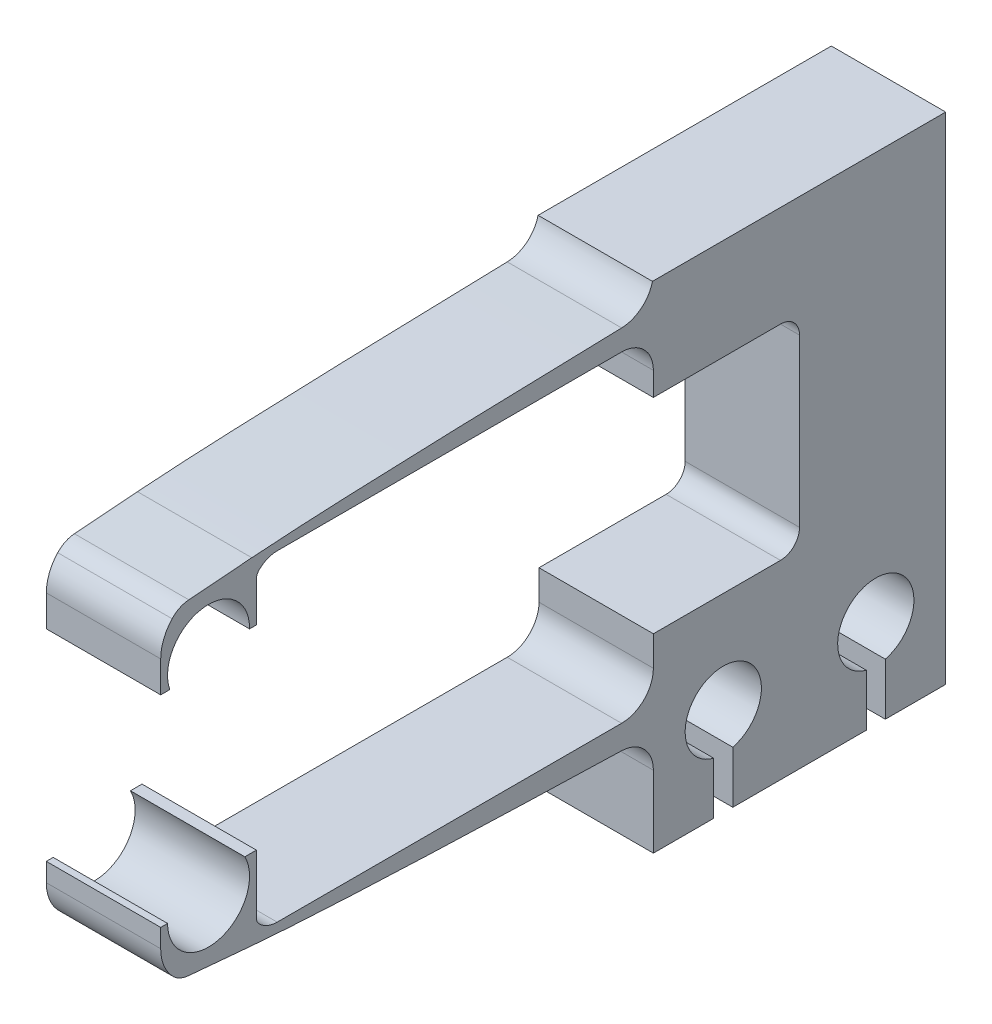
from build123d import *

# Parameters (mm, degrees)
BOSS_EXTRUDE1_DEPTH = 2.25
CUT_EXTRUDE1_DEPTH  = 32.519835025
FILLET1_R           = 0.75
BOSS_EXTRUDE2_DEPTH = 2.25
BOSS_EXTRUDE4_DEPTH = 4.5
FILLET2_R           = 1
CUT_EXTRUDE4_DEPTH  = 5
BOSS_EXTRUDE5_START = -2.25
BOSS_EXTRUDE5_DEPTH = 4.5
SKETCH12_W          = 11.535913892
SKETCH12_H          = 0.5
CUT_EXTRUDE5_DEPTH  = 32.519835168


with BuildPart() as part:
    # Sketch1 → Boss-Extrude1 (new, symmetric)
    with BuildSketch(Plane(origin=(0, 0, 0), x_dir=(0, 0, -1), z_dir=(1, 0, 0))):
        Polygon((17.5, 4.025), (17.5, 4.95), (17.5, 8.301357795), (17.5, 8.5), (29, 8.5), (29, -11.5), (17.5, -11.5), (17.5, -8.673247977), (17.5, -5.2), (17.5, -4.025), (23.25, -4.025), (23.25, 4.025), align=None)
    extrude(amount=BOSS_EXTRUDE1_DEPTH, both=True)

    # Sketch4 → Cut-Extrude1 (cut, through all)
    with BuildSketch(Plane.ZY.offset(2.25)):
        with BuildLine():
            Line((-26.625, -11.5), (-26.625, -9.452368755))
            ThreePointArc((-26.625, -9.452368755), (-26.25, -6.5), (-25.875, -9.452368755))
            Line((-25.875, -9.452368755), (-25.875, -11.5))
            Line((-25.875, -11.5), (-26.625, -11.5))
        make_face()
        with BuildLine():
            Line((-20.625, -9.452368755), (-20.625, -11.5))
            Line((-20.625, -11.5), (-19.875, -11.5))
            Line((-19.875, -11.5), (-19.875, -9.452368755))
            ThreePointArc((-19.875, -9.452368755), (-20.25, -6.5), (-20.625, -9.452368755))
        make_face()
    extrude(amount=-CUT_EXTRUDE1_DEPTH, mode=Mode.SUBTRACT)

    # Fillet1
    fillet1_edges = [part.edges().sort_by_distance(p)[0] for p in [
        (0, -4.025, -23.25),
        (0, 4.025, -23.25),
    ]]
    fillet(fillet1_edges, radius=FILLET1_R)

    # Sketch2 → Boss-Extrude2 (add, symmetric)
    with BuildSketch(Plane(origin=(0, 0, 0), x_dir=(0, 0, -1), z_dir=(1, 0, 0))):
        with BuildLine():
            Line((1.7, -6.45), (16.25, -6.45))
            ThreePointArc((16.25, -6.45), (17.133883476, -6.083883476), (17.5, -5.2))
            Line((17.5, -5.2), (17.5, -8.673247977))
            ThreePointArc((17.5, -8.673247977), (17.136039688, -7.776350438), (16.25, -7.38670191))
            add(Edge.make_bspline(
                [(16.25, -7.38670191), (15.982544989, -7.378993429), (15.453928293, -7.363553213), (14.397933299, -7.332164796), (13.361703255, -7.29957206), (12.100876768, -7.258861503), (10.975898138, -7.220164867), (9.768608213, -7.176905715), (8.611498431, -7.132461764), (7.424019565, -7.084024767), (6.255327605, -7.032148986), (5.075409432, -6.975000615), (3.903033551, -6.911058587), (2.727587922, -6.837381628), (1.722719604, -6.759660724), (0.954287884, -6.683217964), (0.456400256, -6.610639739), (0.237084283, -6.56505431), (0.137087499, -6.537027737), (0.087321771, -6.519206998), (0.060111975, -6.507310883), (0.043000809, -6.498417374), (0.030678751, -6.490921905), (0.01600081, -6.480451435), (0.005229873, -6.469720378), (0.000815287, -6.459042222), (0, -6.45)],
                knots=[0.090617463, 0.090617463, 0.090617463, 0.090617463, 0.090617463, 0.156221583, 0.221825702, 0.287429821, 0.35303394, 0.41863806, 0.484242179, 0.549846298, 0.615450417, 0.681054537, 0.746658656, 0.812262775, 0.877866892, 0.943220604, 0.971682344, 0.984222879, 0.990100446, 0.993094331, 0.994839978, 0.995992112, 0.996718592, 0.997392575, 0.998059613, 1, 1, 1, 1, 1], degree=4))
            Line((0, -6.45), (-1.7, -6.45))
            Line((-1.7, -6.45), (-1.7, -4.45))
            ThreePointArc((-1.7, -4.45), (0, -2.75), (1.7, -4.45))
            Line((1.7, -4.45), (1.7, -6.45))
        make_face()
        with BuildLine():
            Line((17.5, 4.95), (17.5, 8.301357795))
            ThreePointArc((17.5, 8.301357795), (17.135773003, 7.406119792), (16.25, 7.019443472))
            add(Edge.make_bspline(
                [(16.25, 7.019443472), (15.987531738, 7.01282569), (15.470119802, 6.999607493), (14.430987801, 6.972604073), (13.4161389, 6.944724509), (12.177418763, 6.909818433), (11.074067802, 6.876745116), (9.888671574, 6.839769393), (8.753245319, 6.801895235), (7.587539532, 6.760659557), (6.440473735, 6.716696676), (5.282208442, 6.668364938), (4.131254265, 6.614778963), (2.976099529, 6.553298089), (1.935166314, 6.486657721), (1.112090632, 6.419330464), (0.550531612, 6.355136747), (0.26288649, 6.306396396), (0.144856484, 6.278329018), (0.090076692, 6.261554801), (0.061106748, 6.250555216), (0.043474041, 6.242594857), (0.030984848, 6.235965644), (0.016604026, 6.227042793), (0.005627844, 6.21781856), (0.000998515, 6.208209958), (0, 6.2)],
                knots=[0.090678734, 0.090678734, 0.090678734, 0.090678734, 0.090678734, 0.15510723, 0.219535726, 0.283964222, 0.348392717, 0.412821213, 0.477249709, 0.541678205, 0.606106701, 0.670535197, 0.734963692, 0.799392188, 0.863820683, 0.928249179, 0.967999033, 0.983460374, 0.990010293, 0.993269409, 0.995072657, 0.996228288, 0.996922821, 0.997582549, 0.998234329, 1, 1, 1, 1, 1], degree=4))
            Line((0, 6.2), (-1.7, 6.2))
            Line((-1.7, 6.2), (-1.7, 4.2))
            ThreePointArc((-1.7, 4.2), (0, 2.5), (1.7, 4.2))
            Line((1.7, 4.2), (1.7, 6.2))
            Line((1.7, 6.2), (16.25, 6.2))
            ThreePointArc((16.25, 6.2), (17.133883476, 5.833883476), (17.5, 4.95))
        make_face()
    extrude(amount=BOSS_EXTRUDE2_DEPTH, both=True)

    # Sketch3 → Boss-Extrude4 (add, through all)
    with BuildSketch(Plane.ZY.offset(2.25)):
        with BuildLine():
            Line((1.7, -6.45), (-1.690848844, -6.752163217))
            add(Edge.make_bspline(
                [(0, -6.45), (-0.000815287, -6.459042222), (-0.005229873, -6.469720378), (-0.01600081, -6.480451435), (-0.030678751, -6.490921905), (-0.043000809, -6.498417374), (-0.060111975, -6.507310883), (-0.087321771, -6.519206998), (-0.137087499, -6.537027737), (-0.237084283, -6.56505431), (-0.456400256, -6.610639739), (-0.842629924, -6.666941327), (-1.204799072, -6.706915262), (-1.511345405, -6.736167418), (-1.690848844, -6.752163217)],
                knots=[0.090617463, 0.090617463, 0.090617463, 0.090617463, 0.090617463, 0.09255785, 0.093224888, 0.093898872, 0.094625351, 0.095777486, 0.097523132, 0.100517018, 0.106394584, 0.118935119, 0.14739686, 0.187580696, 0.187580696, 0.187580696, 0.187580696, 0.187580696], degree=4))
            Line((0, -6.45), (1.7, -6.45))
        make_face()
        with BuildLine():
            Line((0, 6.2), (1.7, 6.2))
            Line((1.7, 6.2), (-1.70169721, 6.465184862))
            add(Edge.make_bspline(
                [(-1.70169721, 6.465184862), (-1.588493346, 6.45635987), (-1.29771245, 6.43266583), (-0.938114175, 6.399442625), (-0.550531612, 6.355136747), (-0.26288649, 6.306396396), (-0.144856484, 6.278329018), (-0.090076692, 6.261554801), (-0.061106748, 6.250555216), (-0.043474041, 6.242594857), (-0.030984848, 6.235965644), (-0.016604026, 6.227042793), (-0.005627844, 6.21781856), (-0.000998515, 6.208209958), (0, 6.2)],
                knots=[0.902915454, 0.902915454, 0.902915454, 0.902915454, 0.902915454, 0.928249179, 0.967999033, 0.983460374, 0.990010293, 0.993269409, 0.995072657, 0.996228288, 0.996922821, 0.997582549, 0.998234329, 1, 1, 1, 1, 1], degree=4))
        make_face()
    extrude(amount=-BOSS_EXTRUDE4_DEPTH)

    # Fillet2
    fillet2_edges = [part.edges().sort_by_distance(p)[0] for p in [
        (0, -6.45, -1.7),
        (0, -6.45, 1.7),
        (0, 6.2, 1.7),
        (0, 6.2, -1.7),
    ]]
    fillet(fillet2_edges, radius=FILLET2_R)

    # Sketch6 → Cut-Extrude4 (cut, symmetric)
    with BuildSketch(Plane(origin=(0, 0, 0), x_dir=(0, 0, -1), z_dir=(1, 0, 0))):
        with BuildLine():
            Line((-1.6125, -4.3375), (-1.696273489, -4.3375))
            Line((-1.696273489, -4.3375), (-1.696273489, -2.65))
            Line((-1.696273489, -2.65), (1.696273489, -2.65))
            Line((1.696273489, -2.65), (1.696273489, -4.3375))
            Line((1.696273489, -4.3375), (1.6125, -4.3375))
            ThreePointArc((1.6125, -4.3375), (0, -5.95), (-1.6125, -4.3375))
        make_face()
        with BuildLine():
            Line((1.612242467, 4.083682007), (1.696015956, 4.083682007))
            Line((1.696015956, 4.083682007), (1.696015956, 2.396182007))
            Line((1.696015956, 2.396182007), (-1.696015956, 2.396182007))
            Line((-1.696015956, 2.396182007), (-1.696015956, 4.083682007))
            Line((-1.696015956, 4.083682007), (-1.612242467, 4.083682007))
            ThreePointArc((-1.612242467, 4.083682007), (0, 5.725), (1.612242467, 4.083682007))
        make_face()
    extrude(amount=CUT_EXTRUDE4_DEPTH, both=True, mode=Mode.SUBTRACT)

    # Sketch9 → Boss-Extrude5 (add)
    with BuildSketch(Plane(origin=(0, 0, 0), x_dir=(0, 0, -1), z_dir=(1, 0, 0)).offset(BOSS_EXTRUDE5_START)):
        with BuildLine():
            Line((-1.696273489, -4.3375), (-1.8825, -4.3375))
            Line((-1.8825, -4.3375), (-1.8825, -5.065291012))
            ThreePointArc((-1.8825, -5.065291012), (-1.767426598, -5.679381925), (-1.437821002, -6.210145232))
            ThreePointArc((-1.437821002, -6.210145232), (-1.63215369, -5.89721165), (-1.7, -5.535148811))
            Line((-1.7, -5.535148811), (-1.7, -4.45))
            ThreePointArc((-1.7, -4.45), (-1.699068117, -4.393719149), (-1.696273489, -4.3375))
        make_face()
        with BuildLine():
            Line((1.8825, -4.3375), (1.8825, -5.890593975))
            ThreePointArc((1.8825, -5.890593975), (1.911190263, -6.034829666), (1.992893219, -6.157106781))
            ThreePointArc((1.992893219, -6.157106781), (1.776120467, -5.832683432), (1.7, -5.45))
            Line((1.7, -5.45), (1.7, -4.45))
            ThreePointArc((1.7, -4.45), (1.699068117, -4.393719149), (1.696273489, -4.3375))
            Line((1.696273489, -4.3375), (1.6125, -4.3375))
            ThreePointArc((1.6125, -4.3375), (1.565557971, -3.951255919), (1.427464973, -3.5875))
            Line((1.427464973, -3.5875), (1.8825, -3.5875))
            Line((1.8825, -3.5875), (1.8825, -4.3375))
        make_face()
        with BuildLine():
            Line((1.696015956, 4.083682007), (1.882242467, 4.083682007))
            Line((1.882242467, 4.083682007), (1.882242467, 5.639972236))
            ThreePointArc((1.882242467, 5.639972236), (1.910999661, 5.78454441), (1.992893219, 5.907106781))
            ThreePointArc((1.992893219, 5.907106781), (1.776120467, 5.582683432), (1.7, 5.2))
            Line((1.7, 5.2), (1.7, 4.2))
            ThreePointArc((1.7, 4.2), (1.699003697, 4.141806899), (1.696015956, 4.083682007))
        make_face()
        with BuildLine():
            Line((-1.882242467, 4.083682007), (-1.882242467, 4.809550575))
            ThreePointArc((-1.882242467, 4.809550575), (-1.766204889, 5.424085171), (-1.434071123, 5.95399521))
            ThreePointArc((-1.434071123, 5.95399521), (-1.631147443, 5.639565509), (-1.7, 5.274922618))
            Line((-1.7, 5.274922618), (-1.7, 4.2))
            ThreePointArc((-1.7, 4.2), (-1.699003697, 4.141806899), (-1.696015956, 4.083682007))
            Line((-1.696015956, 4.083682007), (-1.612242467, 4.083682007))
            ThreePointArc((-1.612242467, 4.083682007), (-1.587589378, 3.830159396), (-1.523321299, 3.583682007))
            Line((-1.523321299, 3.583682007), (-1.882242467, 3.583682007))
            Line((-1.882242467, 3.583682007), (-1.882242467, 4.083682007))
        make_face()
    extrude(amount=BOSS_EXTRUDE5_DEPTH)

    # Sketch12 → Cut-Extrude5 (cut, through all)
    with BuildSketch(Plane.ZY.offset(2.25)):
        with Locations((-23.232043054, 8.25)):
            Rectangle(SKETCH12_W, SKETCH12_H)
    extrude(amount=-CUT_EXTRUDE5_DEPTH, mode=Mode.SUBTRACT)


solid = part.part
